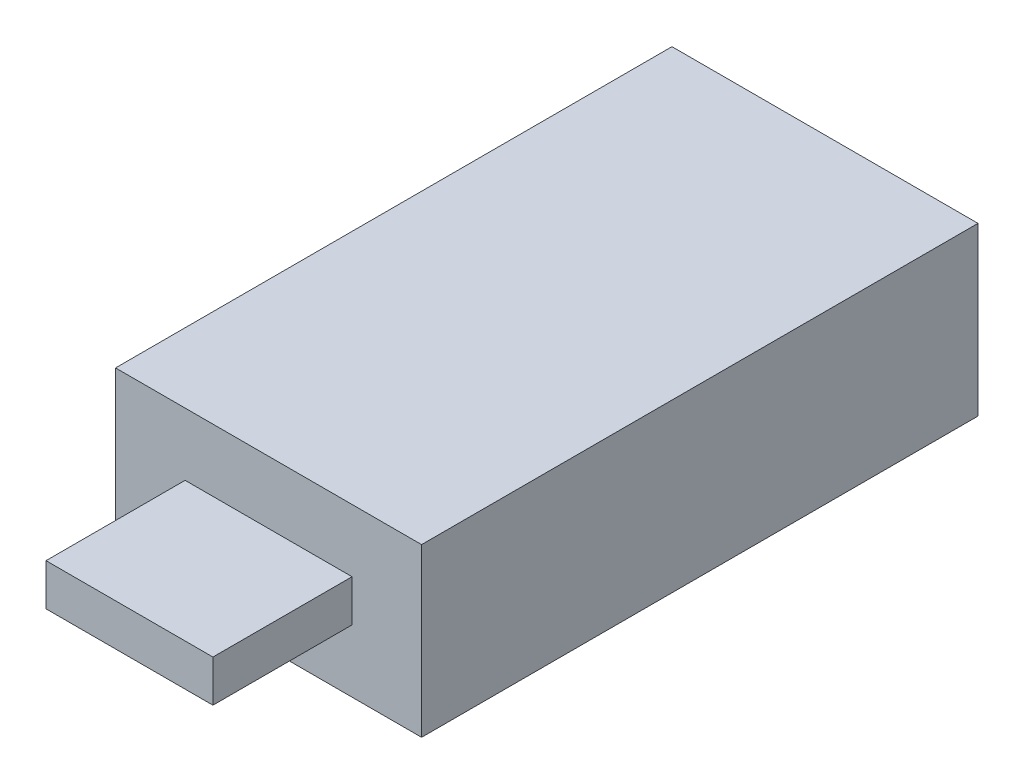
from build123d import *

# Parameters (mm, degrees)
SKETCH1_W           = 22
SKETCH1_H           = 12
BOSS_EXTRUDE1_DEPTH = 40
SKETCH2_W           = 12
SKETCH2_H           = 3
BOSS_EXTRUDE2_DEPTH = 10


with BuildPart() as part:
    # Sketch1 → Boss-Extrude1 (new body)
    with BuildSketch(Plane.XY):
        Rectangle(SKETCH1_W, SKETCH1_H)
    extrude(amount=BOSS_EXTRUDE1_DEPTH)

    # Sketch2 → Boss-Extrude2 (add)
    with BuildSketch(Plane.XY.offset(40)):
        Rectangle(SKETCH2_W, SKETCH2_H)
    extrude(amount=BOSS_EXTRUDE2_DEPTH)


solid = part.part
